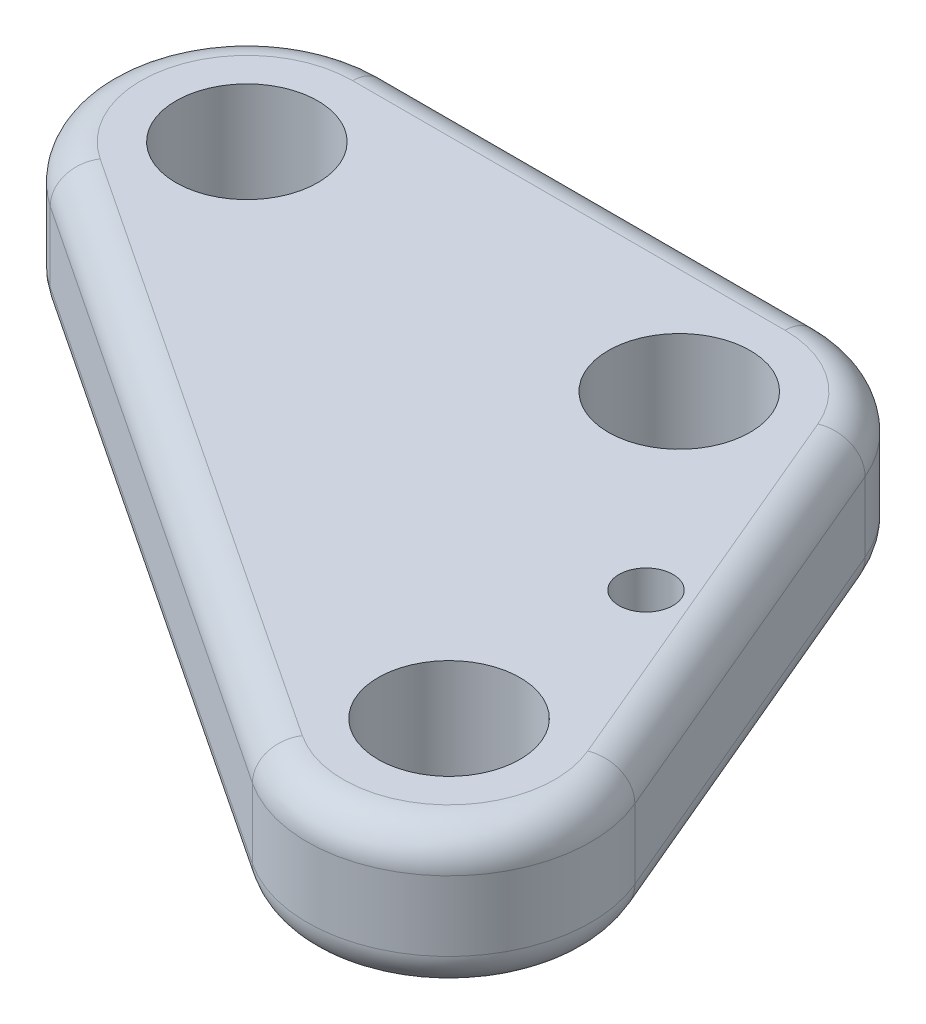
from build123d import *

# Parameters (mm, degrees)
SKETCH1_R           = 5
SKETCH1_R_2         = 1.905
BOSS_EXTRUDE1_DEPTH = 10
FILLET1_R           = 2.54
SCALE1_SCALE        = 0.66


with BuildPart() as part:
    # Sketch1 → Boss-Extrude1 (new body)
    with BuildSketch(Plane(origin=(0, 0, 0), x_dir=(1, 0, 0), z_dir=(0, 1, 0))):
        with BuildLine():
            Line((-36.007707984, -8.333333333), (6.325625349, -36.414089892))
            ThreePointArc((6.325625349, -36.414089892), (18.236180718, -35.778760148), (21.066179973, -24.191867669))
            Line((21.066179973, -24.191867669), (9.21284664, 3.888888889))
            ThreePointArc((9.21284664, 3.888888889), (5.527707984, 8.333333333), (0, 10))
            Line((0, 10), (-30.48, 10))
            ThreePointArc((-30.48, 10), (-40.054271078, 2.886751346), (-36.007707984, -8.333333333))
        make_face()
        with Locations((-30.48, 0)):
            Circle(SKETCH1_R, mode=Mode.SUBTRACT)
        Circle(SKETCH1_R, mode=Mode.SUBTRACT)
        with Locations((11.853333333, -28.080756558)):
            Circle(SKETCH1_R, mode=Mode.SUBTRACT)
        with Locations((10.953276102, -13.297076469)):
            Circle(SKETCH1_R_2, mode=Mode.SUBTRACT)
    extrude(amount=BOSS_EXTRUDE1_DEPTH)

    # Fillet1
    fillet1_edges = [part.edges().sort_by_distance(p)[0] for p in [
        (18.236180718, 10, 35.778760148),
        (15.139513307, 10, 10.15148939),
        (5.527707984, 10, -8.333333333),
        (-15.24, 10, -10),
        (-40.054271078, 10, -2.886751346),
        (-15.24, 0, -10),
        (5.527707984, 0, -8.333333333),
        (15.139513307, 0, 10.15148939),
        (-14.841041317, 10, 22.373711613),
        (18.236180718, 0, 35.778760148),
        (-14.841041317, 0, 22.373711613),
        (-40.054271078, 0, -2.886751346),
    ]]
    fillet(fillet1_edges, radius=FILLET1_R)


with BuildPart() as part_1:
    # Scale1: scaled about (-6.985968974, 5, 10.314628386)
    add(part.part.scale(SCALE1_SCALE).moved(Location((-2.375229451, 1.7, 3.506973651))))


solid = part_1.part
